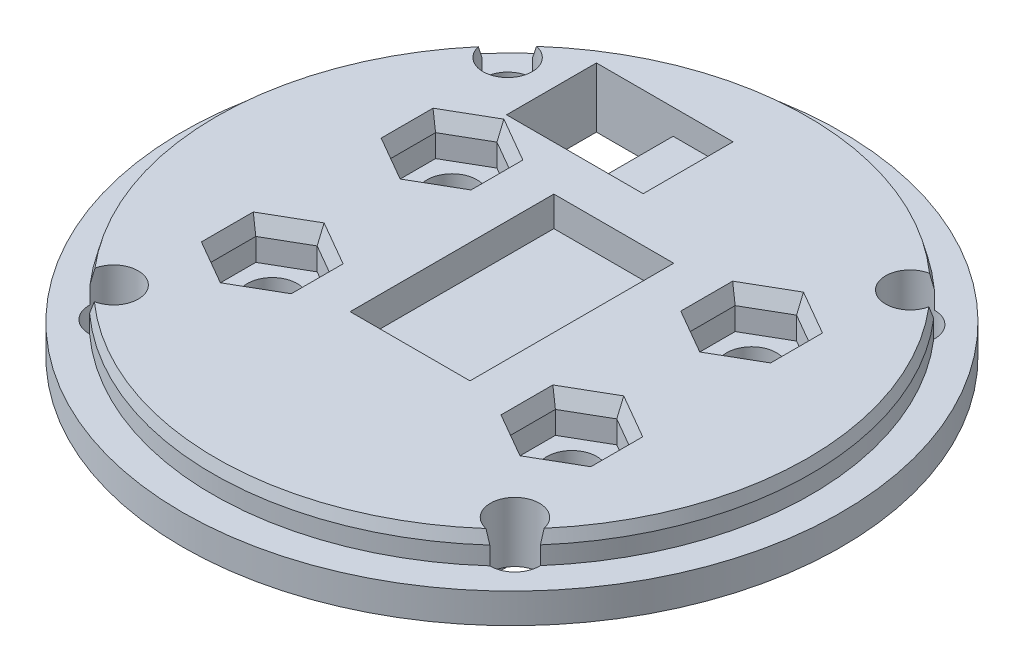
from build123d import *

# Parameters (mm, degrees)
SKETCH_1_R            = 55
EXTRUDE_1_DEPTH       = 5
SKETCH_2_R            = 49.9
EXTRUDE_2_DEPTH       = 5
SKETCH_3_W            = 35
SKETCH_3_H            = 45
EXTRUDE_3_DEPTH       = 25
SKETCH_4_W            = 20.2
SKETCH_4_H            = 10.3
CUT_EXTRUDE_1_DEPTH   = 78.5
SKETCH_5_R            = 4.1
CUT_EXTRUDE_2_DEPTH   = 11
SKETCH_6_R            = 2.75
CUT_EXTRUDE_3_DEPTH   = 36
CHAMFER1_SIZE         = 2
CHAMFER1_SIZE2        = 0.535898385
CHAMFER1_PART_2_SIZE  = 2
CHAMFER1_PART_2_SIZE2 = 0.535898385
CHAMFER1_PART_3_SIZE  = 2
CHAMFER1_PART_3_SIZE2 = 0.535898385
CHAMFER1_PART_4_SIZE  = 2
CHAMFER1_PART_4_SIZE2 = 0.535898385
SKETCH2_W             = 35.065209797
SKETCH2_H             = 45
CUT_EXTRUDE1_DEPTH    = 12.5
BOSS_EXTRUDE1_START   = -2
SKETCH4_W             = 70
SKETCH4_H             = 45
BOSS_EXTRUDE1_DEPTH   = 5.35
SKETCH5_R             = 4.15
CUT_EXTRUDE2_DEPTH    = 16.3500001
CUT_EXTRUDE3_DEPTH    = 6.5
SKETCH7_W             = 20
SKETCH7_H             = 34
CUT_EXTRUDE4_DEPTH    = 5
CHAMFER2_SIZE         = 1
CHAMFER2_SIZE2        = 2.747477419
SKETCH8_W             = 12.8
SKETCH8_H             = 15
CUT_EXTRUDE5_DEPTH    = 11.0000001
SKETCH9_W             = 10
SKETCH9_H             = 15
CUT_EXTRUDE6_DEPTH    = 4.2


with BuildPart() as part:
    # Эскиз1 → Бобышка-Вытянуть1 (new body)
    with BuildSketch(Plane(origin=(0, 0, 0), x_dir=(1, 0, 0), z_dir=(0, 1, 0))):
        Circle(SKETCH_1_R)
    extrude(amount=EXTRUDE_1_DEPTH)

    # Эскиз2 → Бобышка-Вытянуть2 (add)
    with BuildSketch(Plane(origin=(0, 5, 0), x_dir=(1, 0, 0), z_dir=(0, 1, 0))):
        Circle(SKETCH_2_R)
    extrude(amount=EXTRUDE_2_DEPTH)

    # Эскиз3 → Бобышка-Вытянуть3 (add)
    with BuildSketch(Plane.XZ):
        Rectangle(SKETCH_3_W, SKETCH_3_H)
    extrude(amount=EXTRUDE_3_DEPTH)

    # Эскиз4 → Вырез-Вытянуть1 (cut, through all)
    with BuildSketch(Plane.XY.offset(22.5)):
        with Locations((0, -12.5)):
            Rectangle(SKETCH_4_W, SKETCH_4_H)
    extrude(amount=-CUT_EXTRUDE_1_DEPTH, mode=Mode.SUBTRACT)

    # Эскиз5 → Вырез-Вытянуть2 (cut, through all)
    with BuildSketch(Plane.XZ):
        with Locations((33.592198598, -32.871936263)):
            Circle(SKETCH_5_R)
        with Locations((-33.591727056, -32.872418125)):
            Circle(SKETCH_5_R)
        with Locations((-33.591727056, 32.872418125)):
            Circle(SKETCH_5_R)
        with Locations((33.483215177, 32.983215177)):
            Circle(SKETCH_5_R)
    extrude(amount=-CUT_EXTRUDE_2_DEPTH, mode=Mode.SUBTRACT)

    # Эскиз6 → Вырез-Вытянуть3 (cut, through all)
    with BuildSketch(Plane(origin=(0, 10, 0), x_dir=(1, 0, 0), z_dir=(0, 1, 0))):
        with Locations((-17.999799176, 27.999999999)):
            Circle(SKETCH_6_R)
    extrude(amount=-CUT_EXTRUDE_3_DEPTH, mode=Mode.SUBTRACT)

    # Chamfer1
    chamfer1_edges = [part.edges().sort_by_distance(p)[0] for p in [
        (0.000357897, 10, -49.899999999),
    ]]
    chamfer1_side = [part.faces().sort_by_distance(p)[0] for p in [
        (0.000357897, 7.5, -49.899999999),
    ]]
    chamfer(chamfer1_edges, length=CHAMFER1_SIZE, length2=CHAMFER1_SIZE2, reference=chamfer1_side[0])

    # Chamfer1 part 2
    chamfer1_part_2_edges = [part.edges().sort_by_distance(p)[0] for p in [
        (-49.9, 10, 0),
    ]]
    chamfer1_part_2_side = [part.faces().sort_by_distance(p)[0] for p in [
        (-49.9, 7.5, 0),
    ]]
    chamfer(chamfer1_part_2_edges, length=CHAMFER1_PART_2_SIZE, length2=CHAMFER1_PART_2_SIZE2, reference=chamfer1_part_2_side[0])

    # Chamfer1 part 3
    chamfer1_part_3_edges = [part.edges().sort_by_distance(p)[0] for p in [
        (-0.08242255, 10, 49.899931929),
    ]]
    chamfer1_part_3_side = [part.faces().sort_by_distance(p)[0] for p in [
        (-0.08242255, 7.5, 49.899931929),
    ]]
    chamfer(chamfer1_part_3_edges, length=CHAMFER1_PART_3_SIZE, length2=CHAMFER1_PART_3_SIZE2, reference=chamfer1_part_3_side[0])

    # Chamfer1 part 4
    chamfer1_part_4_edges = [part.edges().sort_by_distance(p)[0] for p in [
        (49.899931657, 10, 0.082587101),
    ]]
    chamfer1_part_4_side = [part.faces().sort_by_distance(p)[0] for p in [
        (49.899931657, 7.5, 0.082587101),
    ]]
    chamfer(chamfer1_part_4_edges, length=CHAMFER1_PART_4_SIZE, length2=CHAMFER1_PART_4_SIZE2, reference=chamfer1_part_4_side[0])

    # Sketch2 → Cut-Extrude1 (cut)
    with BuildSketch(Plane.XZ.offset(25)):
        with Locations((-0.032604899, 0)):
            Rectangle(SKETCH2_W, SKETCH2_H)
    extrude(amount=-CUT_EXTRUDE1_DEPTH, mode=Mode.SUBTRACT)

    # Sketch4 → Boss-Extrude1 (add)
    with BuildSketch(Plane.XZ.offset(7.35).offset(BOSS_EXTRUDE1_START)):
        Rectangle(SKETCH4_W, SKETCH4_H)
    extrude(amount=-BOSS_EXTRUDE1_DEPTH)

    # Sketch5 → Cut-Extrude2 (cut, through all)
    with BuildSketch(Plane.XZ.offset(5.35)):
        with Locations((25, 15)):
            Circle(SKETCH5_R)
        with Locations((-25, 15)):
            Circle(SKETCH5_R)
        with Locations((25, -15)):
            Circle(SKETCH5_R)
        with Locations((-25, -15)):
            Circle(SKETCH5_R)
    extrude(amount=-CUT_EXTRUDE2_DEPTH, mode=Mode.SUBTRACT)

    # Sketch6 → Cut-Extrude3 (cut)
    with BuildSketch(Plane(origin=(0, 10, 0), x_dir=(1, 0, 0), z_dir=(0, 1, 0))):
        Polygon((-18.504809472, -11.25), (-25, -7.5), (-31.495190528, -11.25), (-31.495190528, -18.75), (-25, -22.5), (-18.504809472, -18.75), align=None)
        Polygon((31.495190528, -11.25), (25, -7.5), (18.504809472, -11.25), (18.504809472, -18.75), (25, -22.5), (31.495190528, -18.75), align=None)
        Polygon((31.495190528, 18.75), (25, 22.5), (18.504809472, 18.75), (18.504809472, 11.25), (25, 7.5), (31.495190528, 11.25), align=None)
        Polygon((-18.504809472, 18.75), (-25, 22.5), (-31.495190528, 18.75), (-31.495190528, 11.25), (-25, 7.5), (-18.504809472, 11.25), align=None)
    extrude(amount=-CUT_EXTRUDE3_DEPTH, mode=Mode.SUBTRACT)

    # Sketch7 → Cut-Extrude4 (cut)
    with BuildSketch(Plane(origin=(0, 10, 0), x_dir=(1, 0, 0), z_dir=(0, 1, 0))):
        Rectangle(SKETCH7_W, SKETCH7_H)
    extrude(amount=-CUT_EXTRUDE4_DEPTH, mode=Mode.SUBTRACT)

    # Chamfer2
    chamfer2_edges = [part.edges().sort_by_distance(p)[0] for p in [
        (-18.504809472, 10, 15),
        (-21.752404736, 10, 9.375),
        (-28.247595264, 10, 9.375),
        (-31.495190528, 10, 15),
        (-28.247595264, 10, 20.625),
        (-21.752404736, 10, 20.625),
        (31.495190528, 10, 15),
        (28.247595264, 10, 9.375),
        (21.752404736, 10, 9.375),
        (18.504809472, 10, 15),
        (21.752404736, 10, 20.625),
        (28.247595264, 10, 20.625),
        (31.495190528, 10, -15),
        (28.247595264, 10, -20.625),
        (21.752404736, 10, -20.625),
        (18.504809472, 10, -15),
        (21.752404736, 10, -9.375),
        (28.247595264, 10, -9.375),
        (-18.504809472, 10, -15),
        (-21.752404736, 10, -20.625),
        (-28.247595264, 10, -20.625),
        (-31.495190528, 10, -15),
        (-28.247595264, 10, -9.375),
        (-21.752404736, 10, -9.375),
    ]]
    chamfer2_side = [part.faces().sort_by_distance(p)[0] for p in [
        (29.567670169, 10, 29.126140435),
    ]]
    chamfer(chamfer2_edges, length=CHAMFER2_SIZE, length2=CHAMFER2_SIZE2, reference=chamfer2_side[0])

    # Sketch8 → Cut-Extrude5 (cut, through all)
    with BuildSketch(Plane.XZ):
        with Locations((-19, -32)):
            Rectangle(SKETCH8_W, SKETCH8_H)
    extrude(amount=-CUT_EXTRUDE5_DEPTH, mode=Mode.SUBTRACT)

    # Sketch9 → Cut-Extrude6 (cut)
    with BuildSketch(Plane(origin=(0, 10, 0), x_dir=(1, 0, 0), z_dir=(0, 1, 0))):
        with Locations((-7.6, 32)):
            Rectangle(SKETCH9_W, SKETCH9_H)
    extrude(amount=-CUT_EXTRUDE6_DEPTH, mode=Mode.SUBTRACT)


solid = part.part
